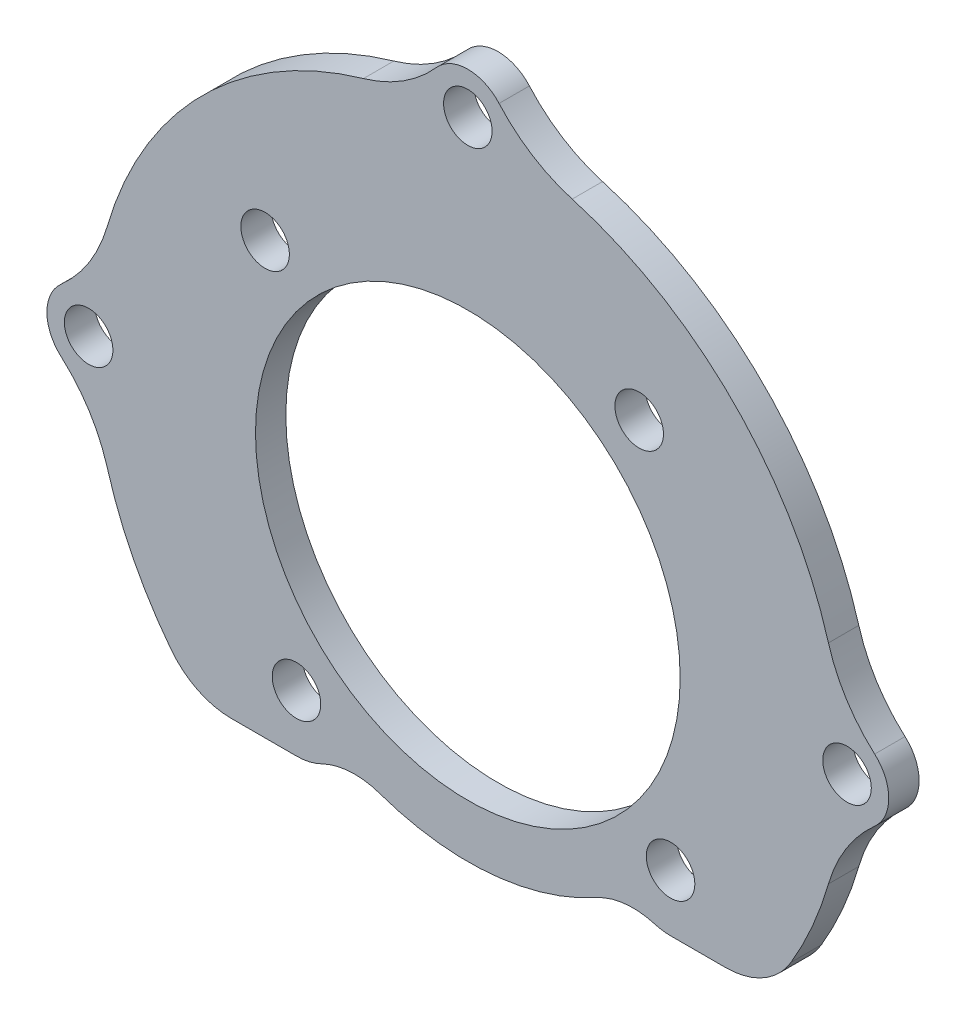
from build123d import *

# Parameters (mm, degrees)
SKETCH1_R           = 25
SKETCH1_R_2         = 3
BOSS_EXTRUDE1_DEPTH = 2
FILLET1_R           = 10
CUT_EXTRUDE1_DEPTH  = 3.0000001
SKETCH4_R           = 1.6
SKETCH4_R_2         = 14
CUT_EXTRUDE2_DEPTH  = 3.0000001
SKETCH6_R           = 1.6
CUT_EXTRUDE3_DEPTH  = 3.0000001
SKETCH7_OUTSIDE_W   = 73.426
SKETCH7_OUTSIDE_H   = 70.426
CUT_EXTRUDE4_DEPTH  = 10
CUT_EXTRUDE5_DEPTH  = 10
FILLET2_R           = 5


with BuildPart() as part:
    # Sketch1 → Boss-Extrude1 (new body)
    with BuildSketch(Plane.XY):
        with Locations((-25, -40.1)):
            Circle(SKETCH1_R)
        with Locations((-50, -40.1)):
            Circle(SKETCH1_R_2)
        with Locations((-50, -40.1)):
            Circle(SKETCH1_R_2)
        with Locations((-25, -40.1)):
            Circle(SKETCH1_R)
        with Locations((0, -40.1)):
            Circle(SKETCH1_R_2)
        with Locations((-25, -40.1)):
            Circle(SKETCH1_R)
        with Locations((-25, -15.1)):
            Circle(SKETCH1_R_2)
        with Locations((-50, -40.1)):
            Circle(SKETCH1_R_2)
        with Locations((-25, -40.1)):
            Circle(SKETCH1_R)
        with Locations((-25, -15.1)):
            Circle(SKETCH1_R_2)
        with Locations((-25, -15.1)):
            Circle(SKETCH1_R_2)
        with Locations((-25, -40.1)):
            Circle(SKETCH1_R)
        with Locations((-25, -40.1)):
            Circle(SKETCH1_R)
        with Locations((0, -40.1)):
            Circle(SKETCH1_R_2)
        with Locations((0, -40.1)):
            Circle(SKETCH1_R_2)
        with Locations((-25, -40.1)):
            Circle(SKETCH1_R)
    extrude(amount=BOSS_EXTRUDE1_DEPTH)

    # Fillet1
    fillet1_edges = [part.edges().sort_by_distance(p)[0] for p in [
        (-49.82, -37.105404869, 1),
        (-27.994595131, -15.28, 1),
        (-22.005404869, -15.28, 1),
        (-0.18, -37.105404869, 1),
        (-0.18, -43.094595131, 1),
        (-49.82, -43.094595131, 1),
    ]]
    fillet(fillet1_edges, radius=FILLET1_R)

    # Sketch3 → Cut-Extrude1 (cut, through all)
    with BuildSketch(Plane.XY.offset(2)):
        with BuildLine():
            ThreePointArc((-37.216735292, -29.767928139), (-37.401620542, -27.65468006), (-39.514868621, -27.83956531))
            ThreePointArc((-39.514868621, -27.83956531), (-39.329983371, -29.952813389), (-37.216735292, -29.767928139))
        make_face()
        with BuildLine():
            ThreePointArc((-35.332071861, -52.316735292), (-37.44531994, -52.501620542), (-37.26043469, -54.614868621))
            ThreePointArc((-37.26043469, -54.614868621), (-35.147186611, -54.429983371), (-35.332071861, -52.316735292))
        make_face()
        with BuildLine():
            ThreePointArc((-12.783264708, -50.432071861), (-12.598379458, -52.54531994), (-10.485131379, -52.36043469))
            ThreePointArc((-10.485131379, -52.36043469), (-10.670016629, -50.247186611), (-12.783264708, -50.432071861))
        make_face()
        with BuildLine():
            ThreePointArc((-14.667928139, -27.883264708), (-12.55468006, -27.698379458), (-12.73956531, -25.585131379))
            ThreePointArc((-12.73956531, -25.585131379), (-14.852813389, -25.770016629), (-14.667928139, -27.883264708))
        make_face()
        with BuildLine():
            ThreePointArc((-35.264995538, -31.48664603), (-33.61335397, -50.364995538), (-14.735004462, -48.71335397))
            ThreePointArc((-14.735004462, -48.71335397), (-16.38664603, -29.835004462), (-35.264995538, -31.48664603))
        make_face()
    extrude(amount=-CUT_EXTRUDE1_DEPTH, mode=Mode.SUBTRACT)

    # Sketch4 → Cut-Extrude2 (cut, through all)
    with BuildSketch(Plane.XY.offset(2)):
        with Locations((-36.296253275, -53.465801956)):
            Circle(SKETCH4_R)
        with Locations((-38.365801956, -28.803746725)):
            Circle(SKETCH4_R)
        with Locations((-13.703746725, -26.734198044)):
            Circle(SKETCH4_R)
        with Locations((-11.634198044, -51.396253275)):
            Circle(SKETCH4_R)
        with Locations((-25, -40.1)):
            Circle(SKETCH4_R_2)
    extrude(amount=-CUT_EXTRUDE2_DEPTH, mode=Mode.SUBTRACT)

    # Sketch6 → Cut-Extrude3 (cut, through all)
    with BuildSketch(Plane.XY.offset(2)):
        with Locations((-50, -40.1)):
            Circle(SKETCH6_R)
        with Locations((-25, -15.1)):
            Circle(SKETCH6_R)
        with Locations((0, -40.1)):
            Circle(SKETCH6_R)
    extrude(amount=-CUT_EXTRUDE3_DEPTH, mode=Mode.SUBTRACT)

    # Sketch7 outside → Cut-Extrude4 (cut)
    with BuildSketch(Plane.XY.offset(2)):
        with Locations((-25, -38.6)):
            Rectangle(SKETCH7_OUTSIDE_W, SKETCH7_OUTSIDE_H)
        with BuildLine():
            ThreePointArc((-31.881324829, -16.325857143), (-42.500892834, -22.599107166), (-48.774142857, -33.218675171))
            ThreePointArc((-48.774142857, -33.218675171), (-49.956443907, -35.846542569), (-51.823461538, -38.041484025))
            ThreePointArc((-51.823461538, -38.041484025), (-52.75, -40.1), (-51.823461538, -42.158515975))
            ThreePointArc((-51.823461538, -42.158515975), (-49.956443907, -44.353457431), (-48.774142857, -46.981324829))
            ThreePointArc((-48.774142857, -46.981324829), (-25, -64.85), (-1.225857143, -46.981324829))
            ThreePointArc((-1.225857143, -46.981324829), (-0.043556093, -44.353457431), (1.823461538, -42.158515975))
            ThreePointArc((1.823461538, -42.158515975), (2.75, -40.1), (1.823461538, -38.041484025))
            ThreePointArc((1.823461538, -38.041484025), (-0.043556093, -35.846542569), (-1.225857143, -33.218675171))
            ThreePointArc((-1.225857143, -33.218675171), (-7.499107166, -22.599107166), (-18.118675171, -16.325857143))
            ThreePointArc((-18.118675171, -16.325857143), (-20.746542569, -15.143556093), (-22.941484025, -13.276538462))
            ThreePointArc((-22.941484025, -13.276538462), (-25, -12.35), (-27.058515975, -13.276538462))
            ThreePointArc((-27.058515975, -13.276538462), (-29.253457431, -15.143556093), (-31.881324829, -16.325857143))
        make_face(mode=Mode.SUBTRACT)
    extrude(amount=-CUT_EXTRUDE4_DEPTH, mode=Mode.SUBTRACT)

    # Sketch8 → Cut-Extrude5 (cut)
    with BuildSketch(Plane.XY.offset(2)):
        with BuildLine():
            ThreePointArc((-33.189286906, -55.565625754), (-34.537253452, -56.777662403), (-36.296253275, -57.215801956))
            Line((-36.296253275, -57.215801956), (-42.877690662, -57.215801956))
            ThreePointArc((-42.877690662, -57.215801956), (-23.637222782, -64.812453101), (-5.348721101, -55.146253275))
            Line((-5.348721101, -55.146253275), (-11.634198044, -55.146253275))
            ThreePointArc((-11.634198044, -55.146253275), (-13.110091293, -54.843605755), (-14.347757645, -53.984514137))
            ThreePointArc((-14.347757645, -53.984514137), (-23.536608094, -57.538706492), (-33.189286906, -55.565625754))
        make_face()
    extrude(amount=-CUT_EXTRUDE5_DEPTH, mode=Mode.SUBTRACT)

    # Fillet2
    fillet2_edges = [part.edges().sort_by_distance(p)[0] for p in [
        (-42.877690662, -57.215801956, 1),
        (-5.348721101, -55.146253275, 1),
        (-14.347757645, -53.984514137, 1),
        (-33.189286906, -55.565625754, 1),
    ]]
    fillet(fillet2_edges, radius=FILLET2_R)


solid = part.part
